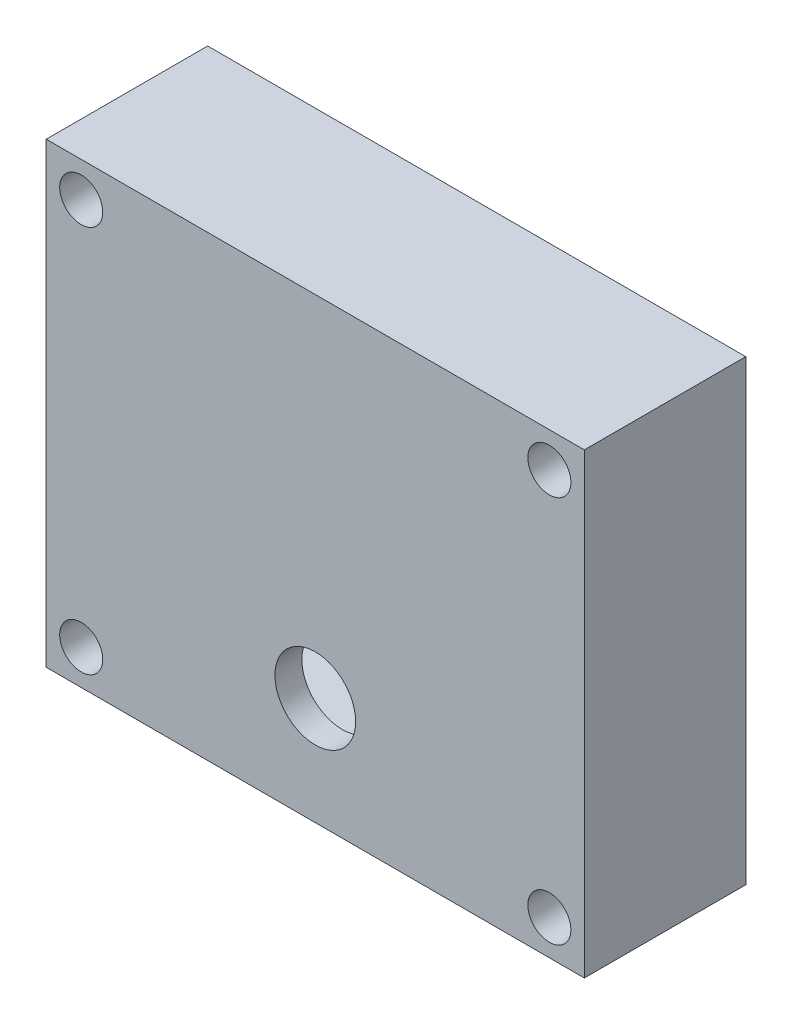
from build123d import *

# Parameters (mm, degrees)
SKETCH1_W           = 100
SKETCH1_H           = 85
BOSS_EXTRUDE1_DEPTH = 30
SKETCH3_R           = 2.5
CUT_EXTRUDE1_DEPTH  = 50
SKETCH4_R           = 4
CUT_EXTRUDE2_DEPTH  = 20
CUT_EXTRUDE5_DEPTH  = 25
SKETCH8_R           = 7.5
CUT_EXTRUDE6_DEPTH  = 31


with BuildPart() as part:
    # Sketch1 → Boss-Extrude1 (new body)
    with BuildSketch(Plane.XY):
        Rectangle(SKETCH1_W, SKETCH1_H)
    extrude(amount=BOSS_EXTRUDE1_DEPTH)

    # Sketch3 → Cut-Extrude1 (cut)
    with BuildSketch(Plane.XY.offset(30)):
        with Locations((-43.5, 36)):
            Circle(SKETCH3_R)
        with Locations((43.5, 36)):
            Circle(SKETCH3_R)
        with Locations((43.5, -36)):
            Circle(SKETCH3_R)
        with Locations((-43.5, -36)):
            Circle(SKETCH3_R)
    extrude(amount=-CUT_EXTRUDE1_DEPTH, mode=Mode.SUBTRACT)

    # Sketch4 → Cut-Extrude2 (cut)
    with BuildSketch(Plane.XY.offset(30)):
        with Locations((-43.5, 36)):
            Circle(SKETCH4_R)
        with Locations((43.5, 36)):
            Circle(SKETCH4_R)
        with Locations((-43.5, -36)):
            Circle(SKETCH4_R)
        with Locations((43.5, -36)):
            Circle(SKETCH4_R)
    extrude(amount=-CUT_EXTRUDE2_DEPTH, mode=Mode.SUBTRACT)

    # Sketch7 → Cut-Extrude5 (cut)
    with BuildSketch(Plane(origin=(0, 0, 0), x_dir=(-1, 0, 0), z_dir=(0, 0, -1))):
        with BuildLine():
            Line((-32, 37), (32, 37))
            ThreePointArc((32, 37), (39.071067812, 34.071067812), (42, 27))
            Line((42, 27), (42, -27))
            ThreePointArc((42, -27), (39.071067812, -34.071067812), (32, -37))
            Line((32, -37), (-32, -37))
            ThreePointArc((-32, -37), (-39.071067812, -34.071067812), (-42, -27))
            Line((-42, -27), (-42, 27))
            ThreePointArc((-42, 27), (-39.071067812, 34.071067812), (-32, 37))
        make_face()
    extrude(amount=-CUT_EXTRUDE5_DEPTH, mode=Mode.SUBTRACT)

    # Sketch8 → Cut-Extrude6 (cut, through all)
    with BuildSketch(Plane.XY.offset(30)):
        with Locations((0, -22.5)):
            Circle(SKETCH8_R)
    extrude(amount=-CUT_EXTRUDE6_DEPTH, mode=Mode.SUBTRACT)


solid = part.part
